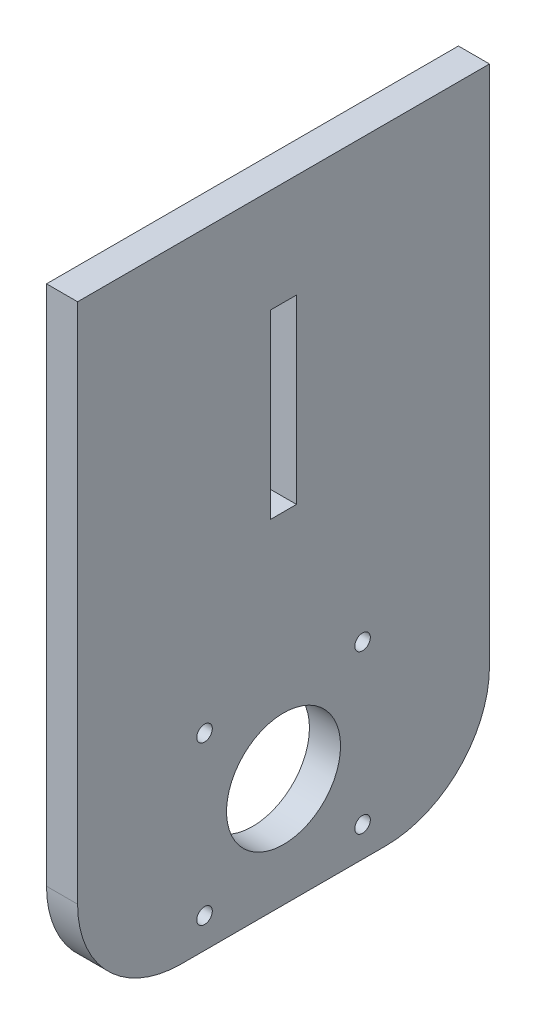
from build123d import *

# Parameters (mm, degrees)
BOSS_EXTRUDE2_DEPTH = 6
SKETCH2_W           = 5
SKETCH2_H           = 35
CUT_EXTRUDE1_DEPTH  = 10
SKETCH3_R           = 11
SKETCH3_R_2         = 1.5
CUT_EXTRUDE2_DEPTH  = 10
FILLET1_R           = 20


with BuildPart() as part:
    # Sketch1 → Boss-Extrude2 (new body)
    with BuildSketch(Plane(origin=(0, 0, 0), x_dir=(0, 0, -1), z_dir=(1, 0, 0))):
        Polygon((0, 43), (0, 120.7), (79.5, 120.7), (79.5, 43), (79.5, 0), (0, 0), align=None)
    extrude(amount=BOSS_EXTRUDE2_DEPTH)

    # Sketch2 → Cut-Extrude1 (cut)
    with BuildSketch(Plane(origin=(6, 0, 0), x_dir=(0, 0, -1), z_dir=(1, 0, 0))):
        with Locations((39.75, 83.2)):
            Rectangle(SKETCH2_W, SKETCH2_H)
    extrude(amount=-CUT_EXTRUDE1_DEPTH, mode=Mode.SUBTRACT)

    # Sketch3 → Cut-Extrude2 (cut)
    with BuildSketch(Plane(origin=(6, 0, 0), x_dir=(0, 0, -1), z_dir=(1, 0, 0))):
        with Locations((39.75, 21.1)):
            Circle(SKETCH3_R)
        with Locations((24.5, 36.35)):
            Circle(SKETCH3_R_2)
        with Locations((55, 36.35)):
            Circle(SKETCH3_R_2)
        with Locations((55, 5.85)):
            Circle(SKETCH3_R_2)
        with Locations((24.5, 5.85)):
            Circle(SKETCH3_R_2)
    extrude(amount=-CUT_EXTRUDE2_DEPTH, mode=Mode.SUBTRACT)

    # Fillet1
    fillet1_edges = [part.edges().sort_by_distance(p)[0] for p in [
        (3, 0, 0),
        (3, 0, -79.5),
    ]]
    fillet(fillet1_edges, radius=FILLET1_R)


solid = part.part
